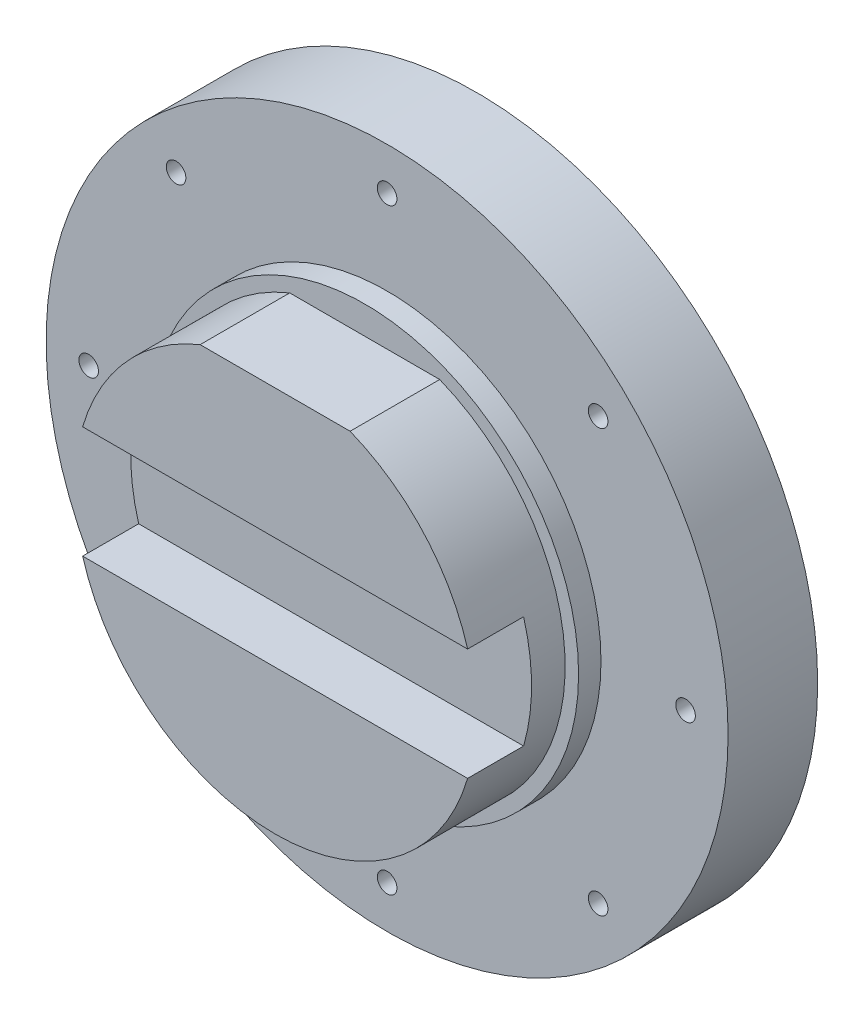
from build123d import *

# Parameters (mm, degrees)
SKETCH1_R           = 304.5
SKETCH1_R_2         = 266.5
SKETCH1_R_3         = 191
BOSS_EXTRUDE2_DEPTH = 80
SKETCH2_R           = 191
BOSS_EXTRUDE3_DEPTH = 20
BOSS_EXTRUDE4_DEPTH = 80
SKETCH4_W           = 368.678721924
SKETCH4_H           = 100
CUT_EXTRUDE1_DEPTH  = 50
SKETCH5_R           = 8.75
CUT_EXTRUDE2_DEPTH  = 130


with BuildPart() as part:
    # Sketch1 → Boss-Extrude2 (new body)
    with BuildSketch(Plane.XY):
        Circle(SKETCH1_R)
        Circle(SKETCH1_R_2, mode=Mode.SUBTRACT)
        Circle(SKETCH1_R_2)
        Circle(SKETCH1_R_3, mode=Mode.SUBTRACT)
    extrude(amount=BOSS_EXTRUDE2_DEPTH)

    # Sketch5 → Cut-Extrude2 (cut)
    with BuildSketch(Plane.XY.offset(180)):
        with Locations((-188.441718833, 188.446195513)):
            Circle(SKETCH5_R)
        with Locations((-266.5, 0)):
            Circle(SKETCH5_R)
        with Locations((-188.441718833, -188.446195513)):
            Circle(SKETCH5_R)
        with Locations((0, -266.5)):
            Circle(SKETCH5_R)
        with Locations((188.441718833, -188.446195513)):
            Circle(SKETCH5_R)
        with Locations((266.5, 0)):
            Circle(SKETCH5_R)
        with Locations((188.441718833, 188.446195513)):
            Circle(SKETCH5_R)
        with Locations((0, 266.5)):
            Circle(SKETCH5_R)
    extrude(amount=-CUT_EXTRUDE2_DEPTH, mode=Mode.SUBTRACT)


with BuildPart() as body_2:
    # Sketch2 → Boss-Extrude3 (new body)
    with BuildSketch(Plane.XY.offset(80)):
        Circle(SKETCH2_R)
        with BuildLine():
            ThreePointArc((-66.970142601, 166), (0, -179), (66.970142601, 166))
            Line((66.970142601, 166), (-66.970142601, 166))
        make_face(mode=Mode.SUBTRACT)
    extrude(amount=BOSS_EXTRUDE3_DEPTH)


with BuildPart() as body_3:
    # Sketch3 → Boss-Extrude4 (new body)
    with BuildSketch(Plane.XY.offset(100)):
        with BuildLine():
            Line((-66.970142601, 166), (66.970142601, 166))
            ThreePointArc((66.970142601, 166), (0, -179), (-66.970142601, 166))
        make_face()
    extrude(amount=BOSS_EXTRUDE4_DEPTH)

    # Sketch4 → Cut-Extrude1 (cut)
    with BuildSketch(Plane.XY.offset(180)):
        Rectangle(SKETCH4_W, SKETCH4_H)
    extrude(amount=-CUT_EXTRUDE1_DEPTH, mode=Mode.SUBTRACT)


solid = Compound([part.part, body_2.part, body_3.part])
